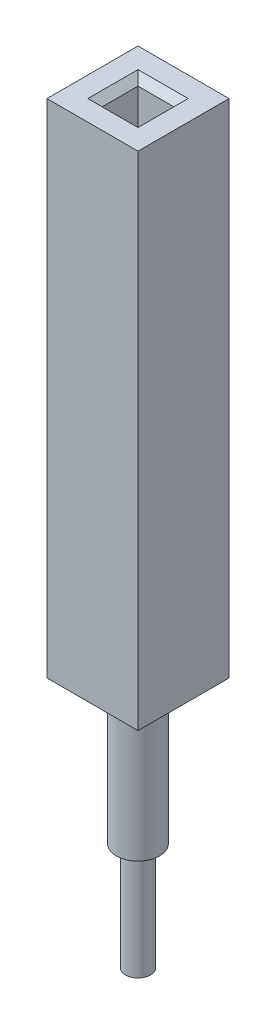
from build123d import *

# Parameters (mm, degrees)
SKETCH_1_W      = 2.54
SKETCH_1_H      = 2.54
SKETCH_1_W_2    = 1
SKETCH_1_H_2    = 1
EXTRUDE_1_DEPTH = 14
CHAMFER_1_SIZE  = 0.2
SKETCH_3_R      = 0.6
EXTRUDE_2_DEPTH = 7
SKETCH_4_R      = 0.35
EXTRUDE_3_DEPTH = 3


with BuildPart() as part:
    # Эскиз1 → Бобышка-Вытянуть1 (new body)
    with BuildSketch(Plane(origin=(0, 0, 0), x_dir=(1, 0, 0), z_dir=(0, 1, 0))):
        Rectangle(SKETCH_1_W, SKETCH_1_H)
        Rectangle(SKETCH_1_W_2, SKETCH_1_H_2, mode=Mode.SUBTRACT)
    extrude(amount=EXTRUDE_1_DEPTH)

    # Фаска1
    chamfer_1_edges = [part.edges().sort_by_distance(p)[0] for p in [
        (0.5, 14, 0),
        (0, 14, -0.5),
        (-0.5, 14, 0),
        (0, 14, 0.5),
    ]]
    chamfer(chamfer_1_edges, length=CHAMFER_1_SIZE)


with BuildPart() as body_2:
    # Эскиз3 → Бобышка-Вытянуть2 (new body)
    with BuildSketch(Plane(origin=(0, 3, 0), x_dir=(-1, 0, 0), z_dir=(0, -1, 0))):
        Circle(SKETCH_3_R)
    extrude(amount=EXTRUDE_2_DEPTH)


with BuildPart() as body_3:
    # Эскиз4 → Бобышка-Вытянуть3 (new body)
    with BuildSketch(Plane.XZ.offset(4)):
        Circle(SKETCH_4_R)
    extrude(amount=EXTRUDE_3_DEPTH)


solid = Compound([part.part, body_2.part, body_3.part])
